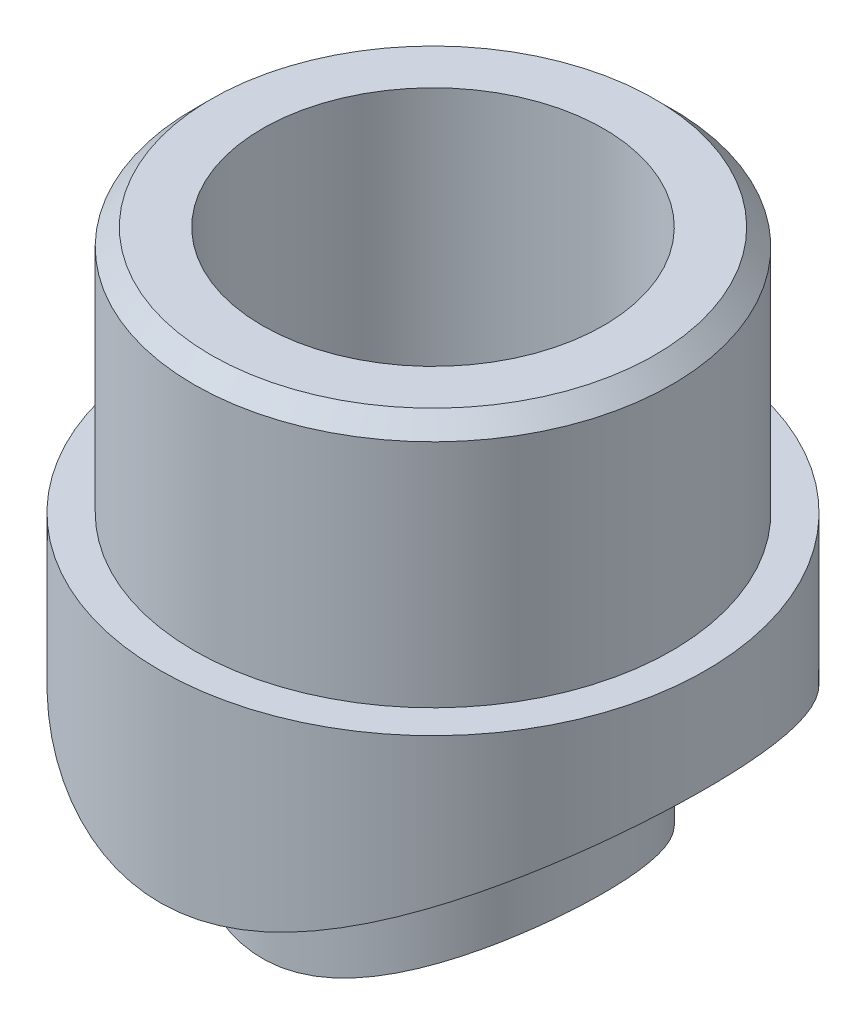
from build123d import *

# Parameters (mm, degrees)
SKETCH1_R               = 16
SKETCH1_R_2             = 6.6
BOSS_EXTRUDE1_DEPTH     = 31
SKETCH2_R               = 14
SKETCH2_R_2             = 10
BOSS_EXTRUDE2_DEPTH     = 14.5
SKETCH3_R               = 25
CUT_EXTRUDE1_DEPTH      = 17
CUT_EXTRUDE1_DEPTH_BACK = 17
BOSS_EXTRUDE3_REACH     = 47.5
SKETCH4_R               = 10
SKETCH4_R_2             = 6.6
SKETCH5_R               = 16.7
CUT_EXTRUDE2_DEPTH      = 17.0000001
CUT_EXTRUDE2_DEPTH_BACK = 17.0000001
CHAMFER1_SIZE           = 1


with BuildPart() as part:
    # Sketch1 → Boss-Extrude1 (new body)
    with BuildSketch(Plane(origin=(0, 0, 0), x_dir=(1, 0, 0), z_dir=(0, 1, 0))):
        Circle(SKETCH1_R)
        Circle(SKETCH1_R_2, mode=Mode.SUBTRACT)
    extrude(amount=BOSS_EXTRUDE1_DEPTH)

    # Sketch2 → Boss-Extrude2 (add)
    with BuildSketch(Plane(origin=(0, 31, 0), x_dir=(1, 0, 0), z_dir=(0, 1, 0))):
        Circle(SKETCH2_R)
        Circle(SKETCH2_R_2, mode=Mode.SUBTRACT)
    extrude(amount=BOSS_EXTRUDE2_DEPTH)

    # Sketch3 → Cut-Extrude1 (cut, two sides)
    with BuildSketch(Plane(origin=(0, 0, 0), x_dir=(0, 0, -1), z_dir=(1, 0, 0))) as cut_extrude1_sk:
        Circle(SKETCH3_R)
    extrude(amount=CUT_EXTRUDE1_DEPTH, mode=Mode.SUBTRACT)
    extrude(cut_extrude1_sk.sketch, amount=-CUT_EXTRUDE1_DEPTH_BACK, mode=Mode.SUBTRACT)

    # Sketch4 → Boss-Extrude3 (add, up to next)
    with BuildSketch(Plane(origin=(0, 0, 0), x_dir=(1, 0, 0), z_dir=(0, 1, 0)), mode=Mode.PRIVATE) as boss_extrude3_sk1:
        Circle(SKETCH4_R)
        Circle(SKETCH4_R_2, mode=Mode.SUBTRACT)
    boss_extrude3_tool1 = extrude(boss_extrude3_sk1.sketch, amount=BOSS_EXTRUDE3_REACH, mode=Mode.PRIVATE) - part.part
    add(boss_extrude3_tool1.solids().sort_by_distance((-9.717157, 0, 0))[0])

    # Sketch5 → Cut-Extrude2 (cut, two sides)
    with BuildSketch(Plane(origin=(0, 0, 0), x_dir=(0, 0, -1), z_dir=(1, 0, 0))) as cut_extrude2_sk:
        Circle(SKETCH5_R)
    extrude(amount=CUT_EXTRUDE2_DEPTH, mode=Mode.SUBTRACT)
    extrude(cut_extrude2_sk.sketch, amount=-CUT_EXTRUDE2_DEPTH_BACK, mode=Mode.SUBTRACT)

    # Chamfer1
    chamfer1_edges = [part.edges().sort_by_distance(p)[0] for p in [
        (-14, 45.5, 0),
    ]]
    chamfer(chamfer1_edges, length=CHAMFER1_SIZE)


solid = part.part
